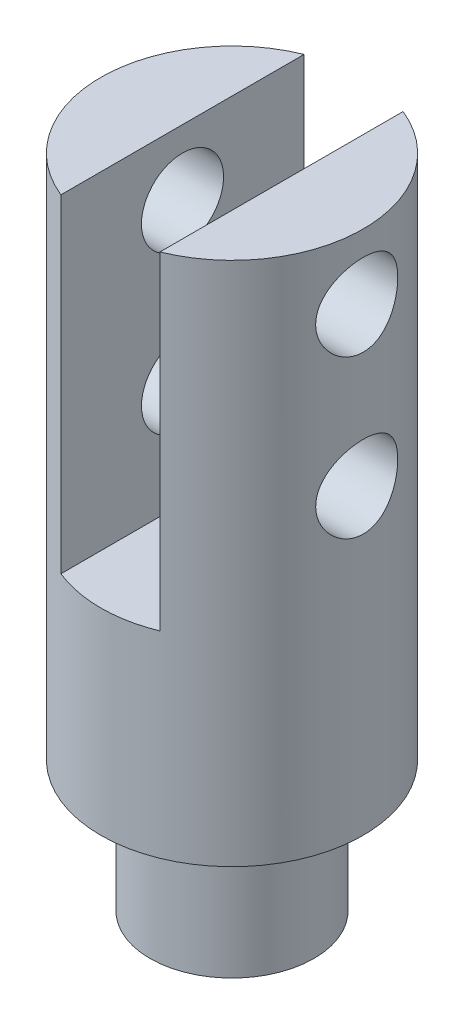
from build123d import *

# Parameters (mm, degrees)
SKETCH3_W          = 9.5758
SKETCH3_H          = 52.44541986
CUT_EXTRUDE2_DEPTH = 31.75
SKETCH4_R          = 3.97256
SKETCH4_R_2        = 3.96875
CUT_EXTRUDE3_DEPTH = 26.4


with BuildPart() as part:
    # Sketch1 → Revolve1 (revolve)
    with BuildSketch(Plane(origin=(0, 0, 0), x_dir=(0, 0, -1), z_dir=(1, 0, 0))):
        Polygon((0, 0), (-12.7, 0), (-12.7, -50.8), (-7.9375, -50.8), (-7.9375, -63.5), (0, -63.5), (0, -50.8), align=None)
    revolve(axis=Axis((0, 54.105122951, 0), (0, -1, 0)))

    # Sketch3 → Cut-Extrude2 (cut)
    with BuildSketch(Plane(origin=(0, 0, 0), x_dir=(1, 0, 0), z_dir=(0, 1, 0))):
        Rectangle(SKETCH3_W, SKETCH3_H)
    extrude(amount=-CUT_EXTRUDE2_DEPTH, mode=Mode.SUBTRACT)

    # Sketch4 → Cut-Extrude3 (cut, through all)
    with BuildSketch(Plane(origin=(12.7, 0, 0), x_dir=(0, 0, -1), z_dir=(1, 0, 0))):
        with Locations((0, -6.35)):
            Circle(SKETCH4_R)
        with Locations((0, -21.59)):
            Circle(SKETCH4_R_2)
    extrude(amount=-CUT_EXTRUDE3_DEPTH, mode=Mode.SUBTRACT)


solid = part.part
